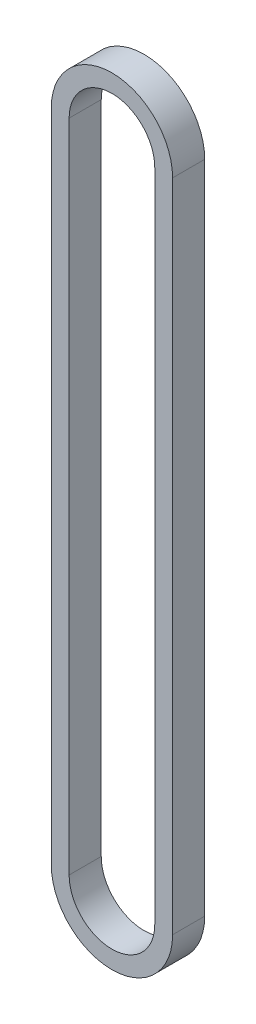
from build123d import *

# Parameters (mm, degrees)
EXTRUDE_1_DEPTH = 4.5


with BuildPart() as part:
    # Эскиз1 → Бобышка-Вытянуть1 (new body)
    with BuildSketch(Plane.XY):
        with BuildLine():
            Line((-8.5, -45.925), (-8.5, 45.925))
            ThreePointArc((-8.5, 45.925), (0, 54.425), (8.5, 45.925))
            Line((8.5, 45.925), (8.5, -45.925))
            ThreePointArc((8.5, -45.925), (0, -54.425), (-8.5, -45.925))
        make_face()
        with BuildLine():
            Line((-6, -45.925), (-6, 45.925))
            ThreePointArc((-6, 45.925), (0, 51.925), (6, 45.925))
            Line((6, 45.925), (6, -45.925))
            ThreePointArc((6, -45.925), (0, -51.925), (-6, -45.925))
        make_face(mode=Mode.SUBTRACT)
    extrude(amount=EXTRUDE_1_DEPTH)


solid = part.part
